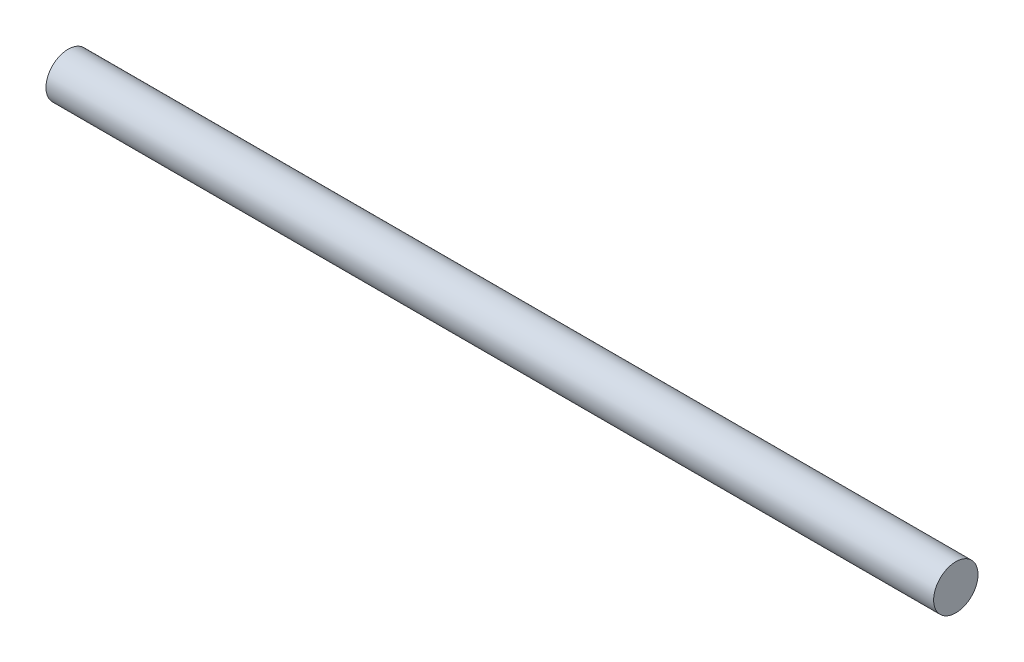
from build123d import *

# Parameters (mm, degrees)
SKETCH1_R           = 1
BOSS_EXTRUDE1_DEPTH = 40


with BuildPart() as part:
    # Sketch1 → Boss-Extrude1 (new body)
    with BuildSketch(Plane(origin=(0, 0, 0), x_dir=(0, 0, -1), z_dir=(1, 0, 0))):
        Circle(SKETCH1_R)
    extrude(amount=BOSS_EXTRUDE1_DEPTH)


solid = part.part
